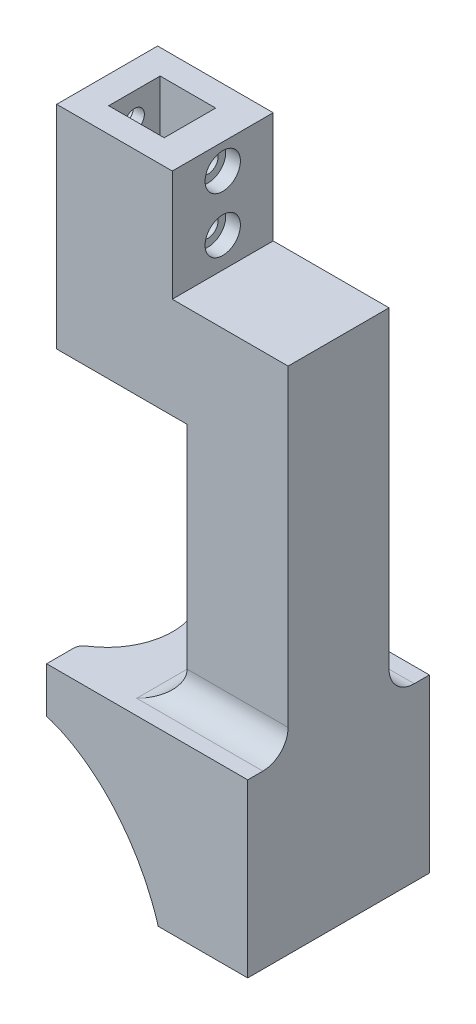
from build123d import *

# Parameters (mm, degrees)
EXTRUDE_6_DEPTH           = 20
SKETCH_6_W                = 17.85
SKETCH_6_H                = 4
EXTRUDE_7_DEPTH           = 8
SKETCH_7_W                = 17.85
SKETCH_7_H                = 4
EXTRUDE_8_DEPTH           = 8
SKETCH_10_R               = 1.975
CUT_EXTRUDE_5_DEPTH       = 23.9
SKETCH_9_W                = 11
SKETCH_9_H                = 10.2
CUT_EXTRUDE_7_DEPTH       = 22
SKETCH_12_R               = 3.5
CUT_EXTRUDE_8_DEPTH       = 2.9
CUT_EXTRUDE_9_DEPTH       = 3.2
EXTRUDE_11_DEPTH          = 4
EXTRUDE_START             = -20
EXTRUDE_12_DEPTH          = 20
CUT_EXTRUDE_12_DEPTH      = 10
SKETCH_20_W               = 6
SKETCH_20_H               = 4
CUT_EXTRUDE_13_DEPTH      = 10
REVOLVE_1_ANGLE           = 180
EXTRUDE_13_DEPTH          = 30
SKETCH_38_W               = 28
SKETCH_38_H               = 8
EXTRUDE_14_DEPTH          = 34
SKETCH_37_W               = 8.80839151
SKETCH_37_H               = 35.661760673
CUT_EXTRUDE_15_DEPTH      = 22.758116413
CUT_EXTRUDE_15_DEPTH_BACK = 58.758116413
SKETCH_40_W               = 21.302771057
SKETCH_40_H               = 34
CUT_EXTRUDE_16_DEPTH      = 7
CUT_EXTRUDE_16_DEPTH_BACK = 40.8500001
SKETCH_42_W               = 6
SKETCH_42_H               = 6
CUT_EXTRUDE_17_DEPTH      = 29.0000001
FILLET_1_R                = 5
FILLET_2_R                = 2


with BuildPart() as part:
    # 스케치1 → 보스-돌출6 (new body)
    with BuildSketch(Plane.XY):
        Polygon((-42.18773019, 15.20361991), (-19.28773019, 15.20361991), (-19.28773019, -6.79638009), (3.66226981, -6.79638009), (3.66226981, -77.79638009), (-42.18773019, -77.79638009), (-42.18773019, -73.79638009), (-16.33773019, -73.79638009), (-16.33773019, -26.79638009), (-42.18773019, -26.79638009), align=None)
    extrude(amount=EXTRUDE_6_DEPTH)

    # 스케치6 → 보스-돌출7 (add)
    with BuildSketch(Plane.XY.offset(20)):
        with Locations((-33.26273019, -75.79638009)):
            Rectangle(SKETCH_6_W, SKETCH_6_H)
    extrude(amount=EXTRUDE_7_DEPTH)

    # 스케치7 → 보스-돌출8 (add)
    with BuildSketch(Plane(origin=(0, 0, 0), x_dir=(-1, 0, 0), z_dir=(0, 0, -1))):
        with Locations((33.26273019, -75.79638009)):
            Rectangle(SKETCH_7_W, SKETCH_7_H)
    extrude(amount=EXTRUDE_8_DEPTH)

    # 스케치10 → 컷-돌출5 (cut, through all)
    with BuildSketch(Plane(origin=(-19.28773019, 0, 0), x_dir=(0, 0, -1), z_dir=(1, 0, 0))):
        with Locations((-10, 10.20361991)):
            Circle(SKETCH_10_R)
        with Locations((-10, -0.79638009)):
            Circle(SKETCH_10_R)
    extrude(amount=-CUT_EXTRUDE_5_DEPTH, mode=Mode.SUBTRACT)

    # 스케치9 → 컷-돌출7 (cut)
    with BuildSketch(Plane(origin=(0, 15.20361991, 0), x_dir=(1, 0, 0), z_dir=(0, 1, 0))):
        with Locations((-31.28773019, -10)):
            Rectangle(SKETCH_9_W, SKETCH_9_H)
    extrude(amount=-CUT_EXTRUDE_7_DEPTH, mode=Mode.SUBTRACT)

    # 스케치12 → 컷-돌출8 (cut)
    with BuildSketch(Plane(origin=(-19.28773019, 0, 0), x_dir=(0, 0, -1), z_dir=(1, 0, 0))):
        with Locations((-10, 10.20361991)):
            Circle(SKETCH_12_R)
        with Locations((-10, -0.79638009)):
            Circle(SKETCH_12_R)
    extrude(amount=-CUT_EXTRUDE_8_DEPTH, mode=Mode.SUBTRACT)

    # 스케치13 → 컷-돌출9 (cut)
    with BuildSketch(Plane.ZY.offset(42.18773019)):
        Polygon((10, 14.360541848), (6.4, 12.282080879), (6.4, 8.12515894), (10, 6.046697971), (13.6, 8.12515894), (13.6, 12.282080879), align=None)
        Polygon((10, 3.360541848), (6.4, 1.282080879), (6.4, -2.87484106), (10, -4.953302029), (13.6, -2.87484106), (13.6, 1.282080879), align=None)
    extrude(amount=-CUT_EXTRUDE_9_DEPTH, mode=Mode.SUBTRACT)

    # 스케치16 → 보스-돌출11 (add)
    with BuildSketch(Plane(origin=(0, -73.79638009, 0), x_dir=(1, 0, 0), z_dir=(0, 1, 0))):
        with BuildLine():
            Line((-16.33773019, -20), (-24.33773019, -20))
            Line((-24.33773019, -20), (-24.33773019, -28))
            ThreePointArc((-24.33773019, -28), (-18.680875941, -25.656854249), (-16.33773019, -20))
        make_face()
        with BuildLine():
            Line((-16.33773019, 0), (-24.33773019, 0))
            Line((-24.33773019, 0), (-24.33773019, 8))
            ThreePointArc((-24.33773019, 8), (-18.680875941, 5.656854249), (-16.33773019, 0))
        make_face()
    extrude(amount=-EXTRUDE_11_DEPTH)

    # 스케치17 → 보스-돌출12 (add)
    with BuildSketch(Plane.XY.offset(20).offset(EXTRUDE_START)):
        with BuildLine():
            Line((-22.33773019, -73.79638009), (-16.33773019, -73.79638009))
            Line((-16.33773019, -73.79638009), (-16.33773019, -67.79638009))
            ThreePointArc((-16.33773019, -67.79638009), (-18.095089503, -72.039020778), (-22.33773019, -73.79638009))
        make_face()
    extrude(amount=EXTRUDE_12_DEPTH)

    # 스케치8 → 컷-돌출12 (cut)
    with BuildSketch(Plane.XZ.offset(77.79638009)):
        with BuildLine():
            Line((-42.18773019, 23), (-42.18773019, -3))
            ThreePointArc((-42.18773019, -3), (-29.18773019, 10), (-42.18773019, 23))
        make_face()
    extrude(amount=-CUT_EXTRUDE_12_DEPTH, mode=Mode.SUBTRACT)

    # 스케치20 → 컷-돌출13 (cut)
    with BuildSketch(Plane.XY.offset(28)):
        with Locations((-39.18773019, -75.79638009)):
            Rectangle(SKETCH_20_W, SKETCH_20_H)
    extrude(amount=-CUT_EXTRUDE_13_DEPTH, mode=Mode.SUBTRACT)

    # 스케치32 → 회전1 (revolve)
    with BuildSketch(Plane.ZY.offset(42.18773019)):
        with BuildLine():
            Line((-8, -77.79638009), (-3, -77.79638009))
            ThreePointArc((-3, -77.79638009), (-15.841250436, -90.997978116), (-23.39066063, -107.79638009))
            Line((-23.39066063, -107.79638009), (-29.758116313, -107.79638009))
            ThreePointArc((-29.758116313, -107.79638009), (-21.866282132, -88.884722246), (-8, -73.79638009))
            Line((-8, -73.79638009), (-8, -77.79638009))
        make_face()
    revolve(axis=Axis((-42.18773019, -67.79638009, 10), (0, -1, 0)), revolution_arc=REVOLVE_1_ANGLE)

    # 스케치33 → 보스-돌출13 (add)
    with BuildSketch(Plane.XZ.offset(77.79638009)):
        with BuildLine():
            Line((3.66226981, 20), (3.66226981, 0))
            Line((3.66226981, 0), (-16.33773019, 0))
            ThreePointArc((-16.33773019, 0), (-18.680875941, -5.656854249), (-24.33773019, -8))
            Line((-24.33773019, -8), (-28.366850202, -8))
            ThreePointArc((-28.366850202, -8), (-19.493750292, 10), (-28.366850202, 28))
            Line((-28.366850202, 28), (-24.33773019, 28))
            ThreePointArc((-24.33773019, 28), (-18.680875941, 25.656854249), (-16.33773019, 20))
            Line((-16.33773019, 20), (3.66226981, 20))
        make_face()
    extrude(amount=EXTRUDE_13_DEPTH)

    # 스케치38 → 보스-돌출14 (add)
    with BuildSketch(Plane(origin=(0, -73.79638009, 0), x_dir=(1, 0, 0), z_dir=(0, 1, 0))):
        with Locations((-10.33773019, 4)):
            Rectangle(SKETCH_38_W, SKETCH_38_H)
        with Locations((-10.33773019, -24)):
            Rectangle(SKETCH_38_W, SKETCH_38_H)
    extrude(amount=-EXTRUDE_14_DEPTH)

    # 스케치39 → 컷-회전1 (revolve, cut)
    with BuildSketch(Plane.ZY.offset(42.18773019)):
        with BuildLine():
            Line((10, -107.79638009), (-23.39066063, -107.79638009))
            ThreePointArc((-23.39066063, -107.79638009), (-15.841250436, -90.997978116), (-3, -77.79638009))
            Line((-3, -77.79638009), (10, -77.79638009))
            Line((10, -77.79638009), (10, -107.79638009))
        make_face()
    revolve(axis=Axis((-42.18773019, -107.79638009, 10), (0, 1, 0)), mode=Mode.SUBTRACT)

    # 스케치37 → 컷-돌출15 (cut, two sides)
    with BuildSketch(Plane.XY.offset(28)) as cut_extrude_15_sk:
        with Locations((-40.591925945, -91.627260427)):
            Rectangle(SKETCH_37_W, SKETCH_37_H)
    extrude(amount=CUT_EXTRUDE_15_DEPTH, mode=Mode.SUBTRACT)
    extrude(cut_extrude_15_sk.sketch, amount=-CUT_EXTRUDE_15_DEPTH_BACK, mode=Mode.SUBTRACT)

    # 스케치40 → 컷-돌출16 (cut, two sides)
    with BuildSketch(Plane.ZY.offset(36.18773019)) as cut_extrude_16_sk:
        with Locations((-18.651385529, -90.79638009)):
            Rectangle(SKETCH_40_W, SKETCH_40_H)
        with Locations((38.651385529, -90.79638009)):
            Rectangle(SKETCH_40_W, SKETCH_40_H)
    extrude(amount=CUT_EXTRUDE_16_DEPTH, mode=Mode.SUBTRACT)
    extrude(cut_extrude_16_sk.sketch, amount=-CUT_EXTRUDE_16_DEPTH_BACK, mode=Mode.SUBTRACT)

    # 스케치42 → 컷-돌출17 (cut, through all)
    with BuildSketch(Plane.XY.offset(20)):
        with Locations((-19.33773019, -70.79638009)):
            Rectangle(SKETCH_42_W, SKETCH_42_H)
    extrude(amount=-CUT_EXTRUDE_17_DEPTH, mode=Mode.SUBTRACT)

    # 필렛1
    fillet_1_edges = [part.edges().sort_by_distance(p)[0] for p in [
        (-6.33773019, -73.79638009, 20),
        (-6.33773019, -73.79638009, 0),
        (-16.33773019, -73.79638009, 10),
    ]]
    fillet(fillet_1_edges, radius=FILLET_1_R)

    # 필렛2
    fillet_2_edges = [part.edges().sort_by_distance(p)[0] for p in [
        (-36.18773019, -75.79638009, 21.532562595),
        (-36.18773019, -75.79638009, -1.532562595),
    ]]
    fillet(fillet_2_edges, radius=FILLET_2_R)


solid = part.part
